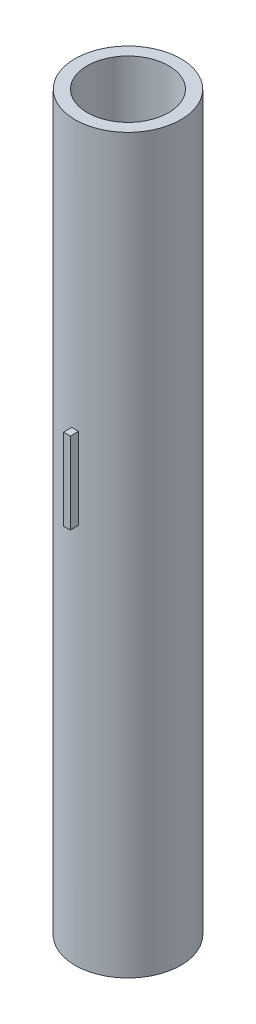
from build123d import *

# Parameters (mm, degrees)
SKETCH1_R           = 19.5
SKETCH1_R_2         = 15
BOSS_EXTRUDE1_DEPTH = 270
SKETCH3_W           = 2.5
SKETCH3_H           = 30
BOSS_EXTRUDE2_DEPTH = 6


with BuildPart() as part:
    # Sketch1 → Boss-Extrude1 (new body)
    with BuildSketch(Plane(origin=(0, 0, 0), x_dir=(1, 0, 0), z_dir=(0, 1, 0))):
        Circle(SKETCH1_R)
        Circle(SKETCH1_R_2, mode=Mode.SUBTRACT)
    extrude(amount=BOSS_EXTRUDE1_DEPTH)

    # Sketch3 → Boss-Extrude2 (add)
    with BuildSketch(Plane.XY.offset(22.5)):
        with Locations((0, 156.116903923)):
            Rectangle(SKETCH3_W, SKETCH3_H)
    extrude(amount=-BOSS_EXTRUDE2_DEPTH)


solid = part.part
